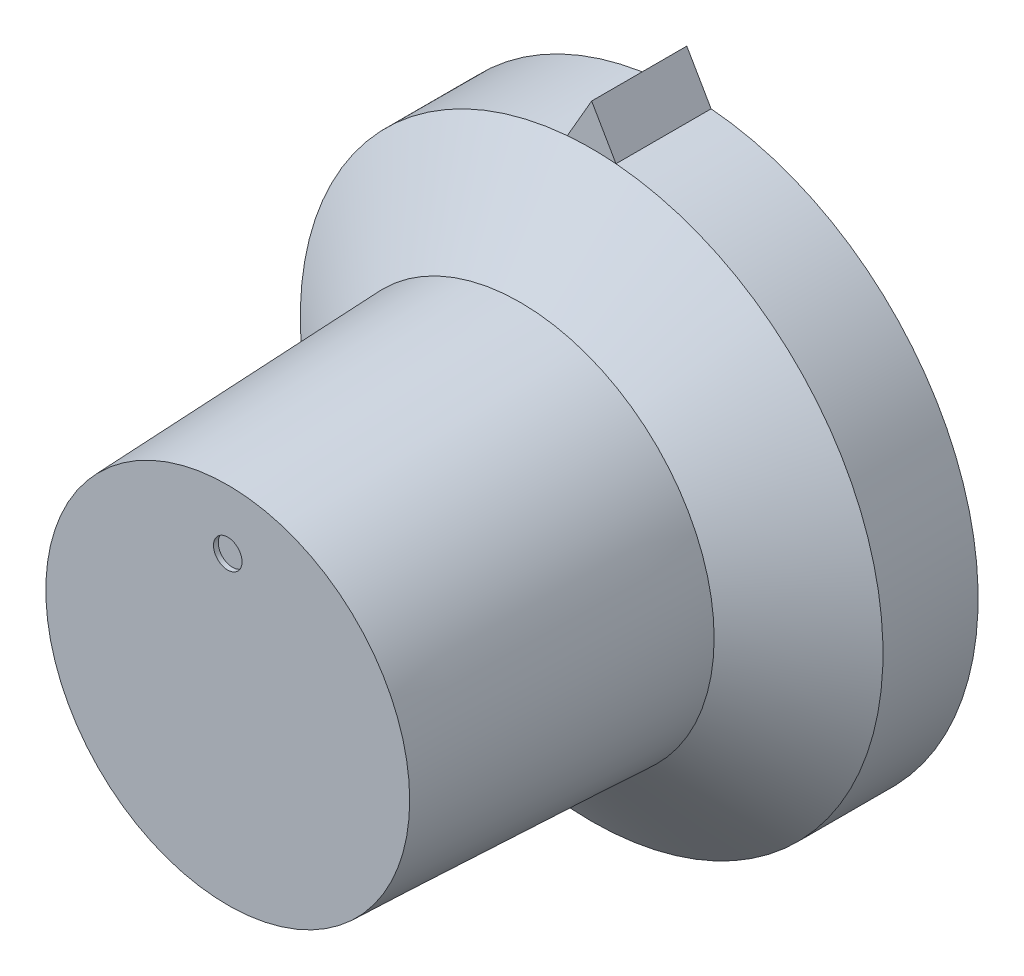
from build123d import *

# Parameters (mm, degrees)
SKETCH2_ONE_SIDE_W  = 4
SKETCH2_ONE_SIDE_H  = 12.25
BOSS_EXTRUDE1_DEPTH = 4
SKETCH4_R           = 0.6
CUT_EXTRUDE1_DEPTH  = 0.2
SKETCH5_R           = 11
CUT_EXTRUDE2_DEPTH  = 4
SKETCH6_R           = 3
CUT_EXTRUDE3_DEPTH  = 11


with BuildPart() as part:
    # Sketch2 one side → Revolve3 (revolve)
    with BuildSketch(Plane(origin=(0, 0, 0), x_dir=(0, 0, -1), z_dir=(1, 0, 0))):
        Polygon((12.3, 0), (12.3, 8.15), (0, 7.65), (0, 0), align=None)
        Polygon((15.3, 0), (15.3, 12.25), (12.3, 8.15), (12.3, 0), align=None)
        with Locations((17.3, 6.125)):
            Rectangle(SKETCH2_ONE_SIDE_W, SKETCH2_ONE_SIDE_H)
    revolve(axis=Axis((0, 0, 0), (0, 0, -1)))

    # Sketch3 → Boss-Extrude1 (add)
    with BuildSketch(Plane(origin=(0, 0, -19.3), x_dir=(-1, 0, 0), z_dir=(0, 0, -1))):
        Polygon((0, 13.98), (1.154700538, 11.98), (-1.154700538, 11.98), align=None)
    extrude(amount=-BOSS_EXTRUDE1_DEPTH)

    # Sketch4 → Cut-Extrude1 (cut)
    with BuildSketch(Plane.XY):
        with Locations((0, 5.15)):
            Circle(SKETCH4_R)
    extrude(amount=-CUT_EXTRUDE1_DEPTH, mode=Mode.SUBTRACT)

    # Sketch5 → Cut-Extrude2 (cut)
    with BuildSketch(Plane(origin=(0, 0, -19.3), x_dir=(-1, 0, 0), z_dir=(0, 0, -1))):
        Circle(SKETCH5_R)
    extrude(amount=-CUT_EXTRUDE2_DEPTH, mode=Mode.SUBTRACT)

    # Sketch6 → Cut-Extrude3 (cut)
    with BuildSketch(Plane(origin=(0, 0, -15.3), x_dir=(-1, 0, 0), z_dir=(0, 0, -1))):
        Circle(SKETCH6_R)
    extrude(amount=-CUT_EXTRUDE3_DEPTH, mode=Mode.SUBTRACT)


solid = part.part
